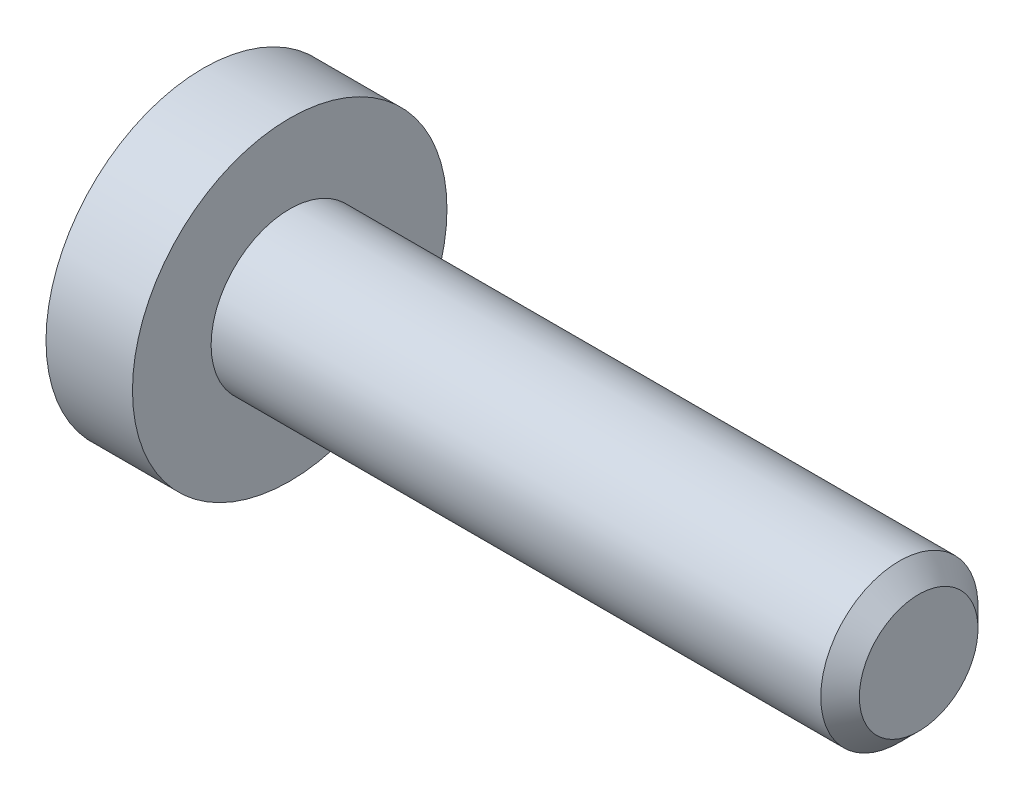
from build123d import *

# Parameters (mm, degrees)
CUT_EXTRUDE1_DEPTH = 1.2


with BuildPart() as part:
    # Sketch1 → Revolve1 (revolve)
    with BuildSketch(Plane.XY):
        Polygon((-1.1, 0), (-1.1, 2), (0, 2), (0, 1), (7.7545, 1), (8, 0.7545), (8, 0), align=None)
    revolve(axis=Axis((8, 0, 0), (-1, 0, 0)))

    # Sketch2 → Cut-Extrude1 (cut)
    with BuildSketch(Plane(origin=(-1.1, 0, 0), x_dir=(0, 0, -1), z_dir=(1, 0, 0))):
        Polygon((-0.65, -0.375277675), (0, -0.75055535), (0.65, -0.375277675), (0.65, 0.375277675), (0, 0.75055535), (-0.65, 0.375277675), align=None)
    extrude(amount=CUT_EXTRUDE1_DEPTH, mode=Mode.SUBTRACT)


solid = part.part
